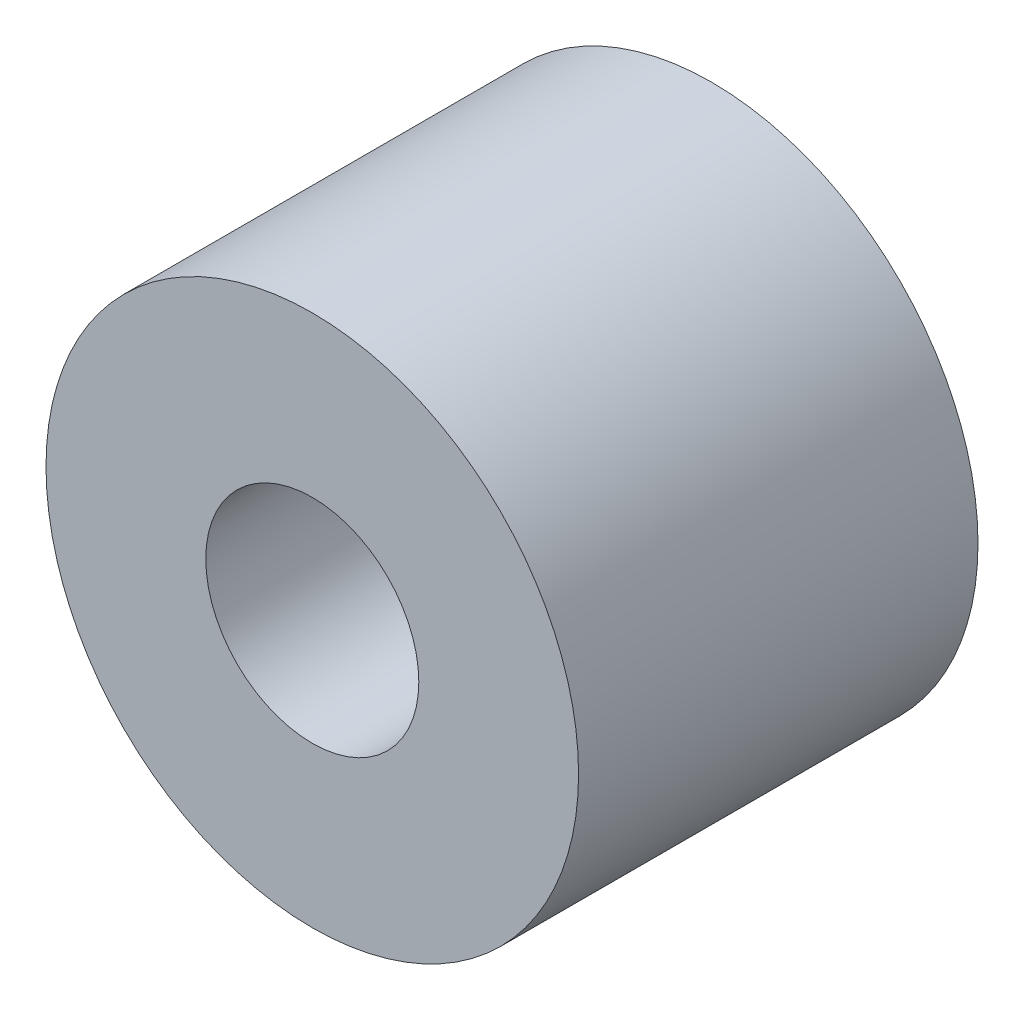
from build123d import *

# Parameters (mm, degrees)
SKETCH_1_R      = 10
SKETCH_1_R_2    = 4
EXTRUDE_1_DEPTH = 15


with BuildPart() as part:
    # 草图1 → 凸台-拉伸1 (new body)
    with BuildSketch(Plane.XY):
        Circle(SKETCH_1_R)
        Circle(SKETCH_1_R_2, mode=Mode.SUBTRACT)
    extrude(amount=EXTRUDE_1_DEPTH)


solid = part.part
